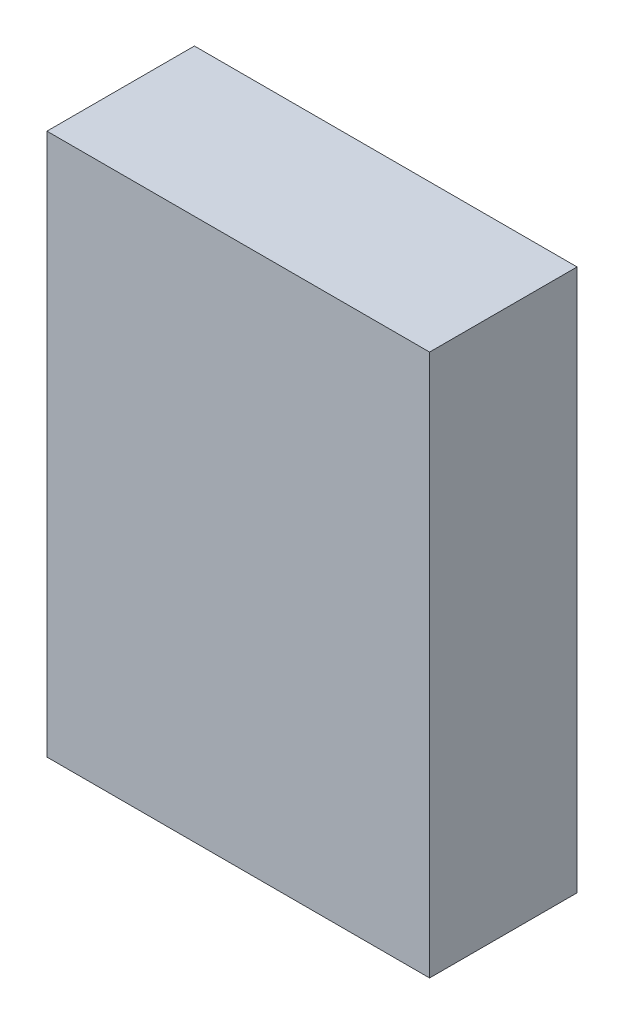
from build123d import *

# Parameters (mm, degrees)
ESQUISSE1_W        = 48
ESQUISSE1_H        = 68
BOSS_EXTRU_1_DEPTH = 18.5
ESQUISSE2_W        = 8
ESQUISSE2_H        = 4
BOSS_EXTRU_2_DEPTH = 2


with BuildPart() as part:
    # Esquisse1 → Boss.-Extru.1 (new body)
    with BuildSketch(Plane.XY):
        Rectangle(ESQUISSE1_W, ESQUISSE1_H)
    extrude(amount=BOSS_EXTRU_1_DEPTH)

    # Esquisse2 → Boss.-Extru.2 (add)
    with BuildSketch(Plane(origin=(0, 0, 0), x_dir=(-1, 0, 0), z_dir=(0, 0, -1))):
        with Locations((14, 29)):
            Rectangle(ESQUISSE2_W, ESQUISSE2_H)
    extrude(amount=BOSS_EXTRU_2_DEPTH)


solid = part.part
